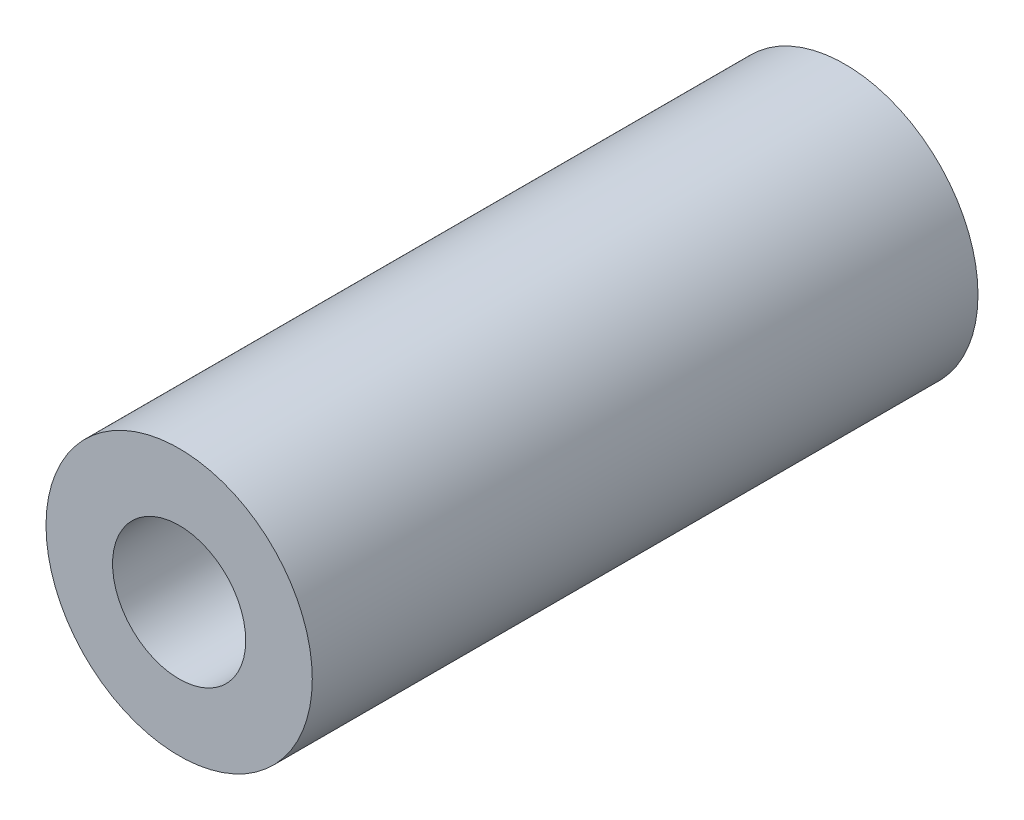
from build123d import *

# Parameters (mm, degrees)
SKETCH1_R           = 4
SKETCH1_R_2         = 2
BOSS_EXTRUDE1_DEPTH = 20


with BuildPart() as part:
    # Sketch1 → Boss-Extrude1 (new body)
    with BuildSketch(Plane.XY):
        Circle(SKETCH1_R)
        Circle(SKETCH1_R_2, mode=Mode.SUBTRACT)
    extrude(amount=BOSS_EXTRUDE1_DEPTH)


solid = part.part
